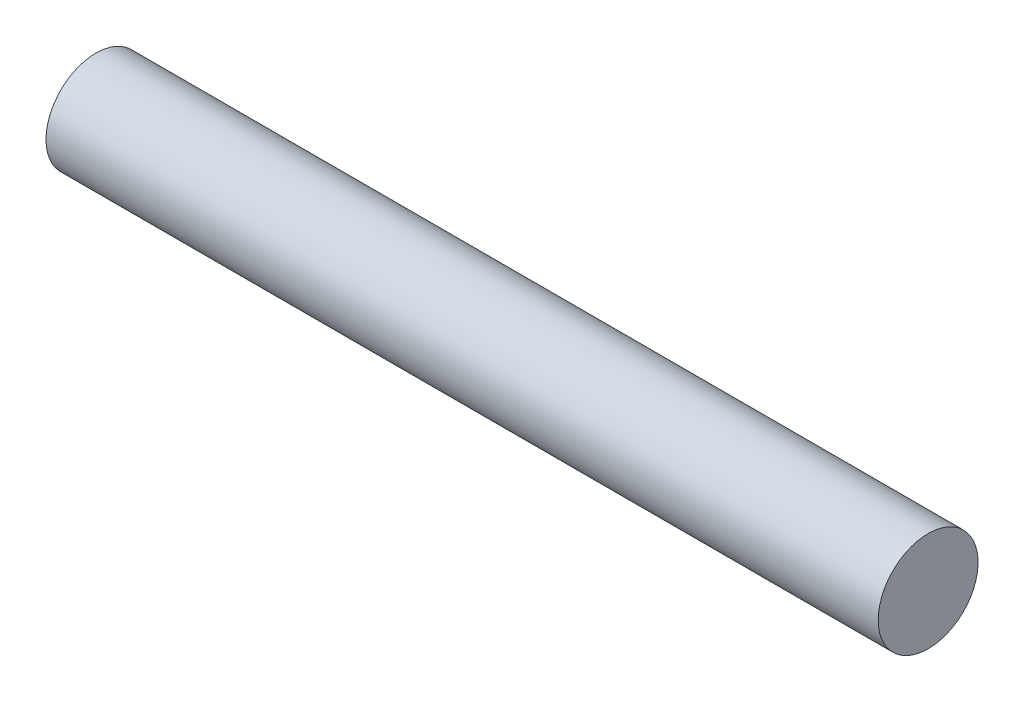
from build123d import *

# Parameters (mm, degrees)
SKETCH1_W = 200
SKETCH1_H = 12


with BuildPart() as part:
    # Sketch1 → Revolve1 (revolve)
    with BuildSketch(Plane(origin=(0, 0, 0), x_dir=(1, 0, 0), z_dir=(0, 1, 0))):
        with Locations((100, 6)):
            Rectangle(SKETCH1_W, SKETCH1_H)
    revolve(axis=Axis((0, 0, 0), (1, 0, 0)))


solid = part.part
